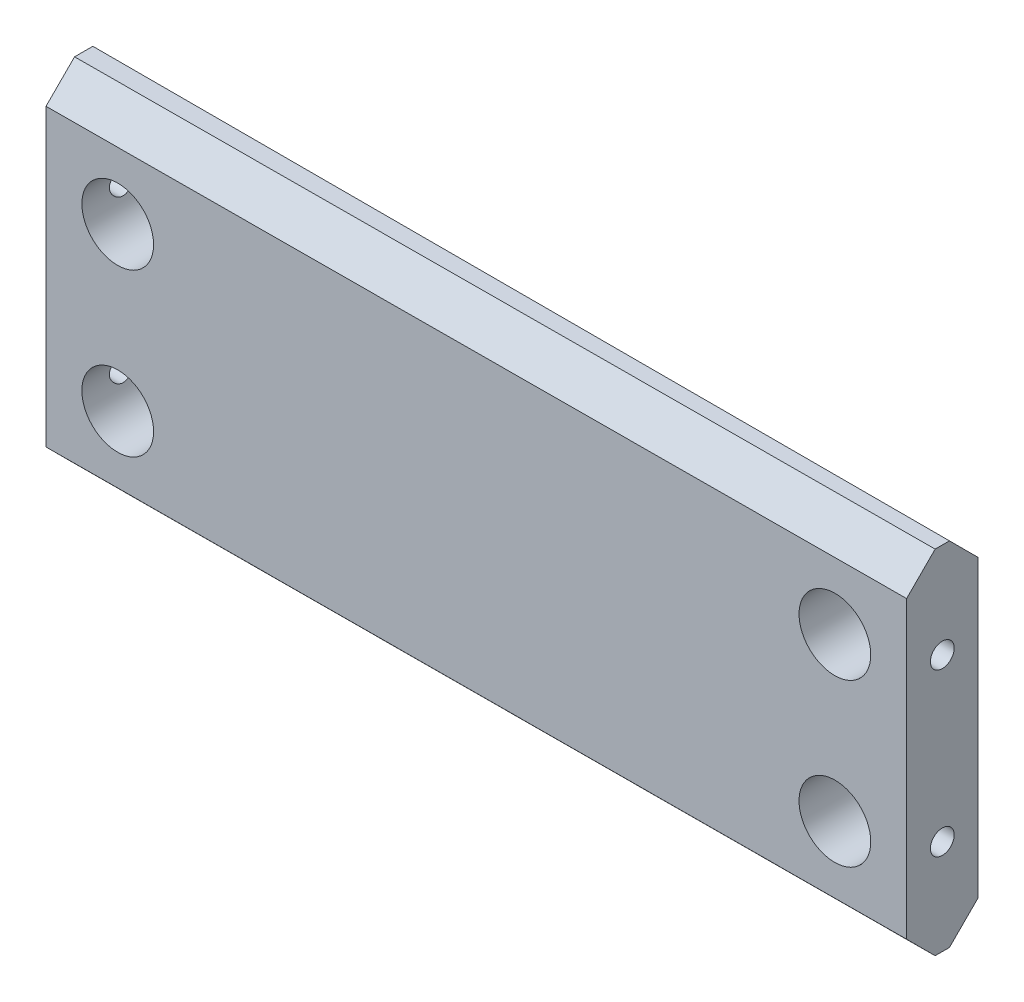
from build123d import *

# Parameters (mm, degrees)
BOSS_EXTRUDE3_DEPTH                  = 46.99
CHAMFER1_SIZE                        = 7.62
F_3_4_0_75_DIAMETER_HOLE1_AT_2_COUNT = 2
F_3_4_0_75_DIAMETER_HOLE1_AT_2_PITCH = 190.5


with BuildPart() as part:
    # 3DSketch2 → Boss-Extrude3 (new, symmetric)
    with BuildSketch(Plane(origin=(-117.411769765, 0, -9.784420547), x_dir=(0.9965456835069088, 0, 0.08304637670451492), z_dir=(0, -1, 0))):
        Polygon((0, 0), (227.81034325, -18.984401715), (229.389897471, 0), (1.670602813, 20.047015755), align=None)
    extrude(amount=BOSS_EXTRUDE3_DEPTH, both=True)

    # Chamfer1
    chamfer1_edges = [part.edges().sort_by_distance(p)[0] for p in [
        (-3.111769765, 46.99, -9.784420547),
        (-3.113013683, -46.99, 9.798831636),
        (-3.111769765, -46.99, -9.784420547),
        (-3.113013683, 46.99, 9.798831636),
    ]]
    chamfer(chamfer1_edges, length=CHAMFER1_SIZE)

    # Sketch3 → 3/4 (0.75) Diameter Hole1 (revolve, cut)
    with BuildSketch(Plane(origin=(92.135949719, -21.59, 9.354454682), x_dir=(0.9999891170795402, 0, -0.0046653748490357765), z_dir=(0, 1, 0))):
        Polygon((0, 0), (0, 24.773197396), (9.525, 19.05), (9.525, 0), align=None)
    f_3_4_0_75_diameter_hole1 = revolve(axis=Axis((92.165574849, -21.59, 15.704385575), (-0.004665374849035791, 0, -0.9999891170795401)), mode=Mode.SUBTRACT)

    # 3/4 (0.75) Diameter Hole1 at 2: 3/4 (0.75) Diameter Hole1 ×2
    with Locations(*[Vector(-0.9999891170795401, 0, 0.004665374849035796) * (i * F_3_4_0_75_DIAMETER_HOLE1_AT_2_PITCH) for i in range(1, F_3_4_0_75_DIAMETER_HOLE1_AT_2_COUNT)]):
        add(f_3_4_0_75_diameter_hole1, mode=Mode.SUBTRACT)

    # Sketch5 → 1/4 (0.25) Diameter Hole1 (revolve, cut)
    with BuildSketch(Plane(origin=(111.186986317, -21.59, -0.259420628), x_dir=(0.00013059504552427994, 0, -0.9999999914724671), z_dir=(0, 1, 0))):
        Polygon((0, 0), (0, 20.957732465), (3.175, 19.05), (3.175, 0), align=None)
    f_1_4_0_25_diameter_hole1 = revolve(axis=Axis((117.536986263, -21.59, -0.258591349), (-0.9999999914724671, 0, -0.00013059504552427964)), mode=Mode.SUBTRACT)

    # Sketch7 → 1/4 (0.25) Diameter Hole2 (revolve, cut)
    with BuildSketch(Plane(origin=(-117.411769765, -21.59, -0.259420547), x_dir=(0, 0, 1), z_dir=(0, 1, 0))):
        Polygon((0, 0), (0, 20.957732465), (3.175, 19.05), (3.175, 0), align=None)
    f_1_4_0_25_diameter_hole2 = revolve(axis=Axis((-123.761769765, -21.59, -0.259420547), (1, 0, 0)), mode=Mode.SUBTRACT)

    # Mirror9: 3/4 (0.75) Diameter Hole1, 1/4 (0.25) Diameter Hole1, 1/4 (0.25) Diameter Hole2 across plane
    add(f_3_4_0_75_diameter_hole1.mirror(Plane.ZX), mode=Mode.SUBTRACT)
    add(f_1_4_0_25_diameter_hole1.mirror(Plane.ZX), mode=Mode.SUBTRACT)
    add(f_1_4_0_25_diameter_hole2.mirror(Plane.ZX), mode=Mode.SUBTRACT)

    # Mirror9 copy 1 sketch → Mirror9 copy 1 (revolve, cut)
    with BuildSketch(Plane(origin=(-98.361977085, 21.59, 10.24320859), x_dir=(0.9999891170795402, 0, -0.0046653748490357765), z_dir=(0, -1, 0))):
        Polygon((0, 0), (0, -24.773197396), (9.525, -19.05), (9.525, 0), align=None)
    revolve(axis=Axis((-98.332351955, 21.59, 16.593139484), (0.004665374849035791, 0, 0.9999891170795401)), mode=Mode.SUBTRACT)


solid = part.part
